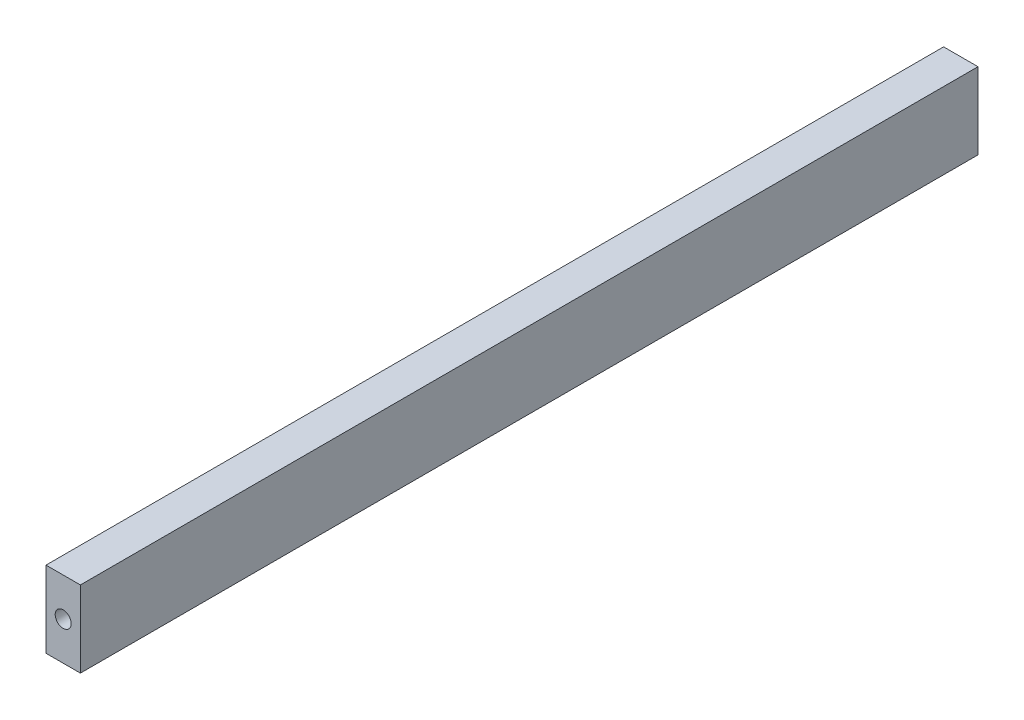
from build123d import *

# Parameters (mm, degrees)
SKETCH1_W           = 9
SKETCH1_H           = 20
BOSS_EXTRUDE1_DEPTH = 117.5
SKETCH2_R           = 2.1
CUT_EXTRUDE1_DEPTH  = 11


with BuildPart() as part:
    # Sketch1 → Boss-Extrude1 (new body, symmetric)
    with BuildSketch(Plane.XY):
        Rectangle(SKETCH1_W, SKETCH1_H)
    extrude(amount=BOSS_EXTRUDE1_DEPTH, both=True)

    # Sketch2 → Cut-Extrude1 (cut)
    with BuildSketch(Plane.XY.offset(117.5)):
        Circle(SKETCH2_R)
    cut_extrude1 = extrude(amount=-CUT_EXTRUDE1_DEPTH, mode=Mode.SUBTRACT)

    # Mirror1: Cut-Extrude1 across plane
    add(cut_extrude1.mirror(Plane.XY), mode=Mode.SUBTRACT)


solid = part.part
